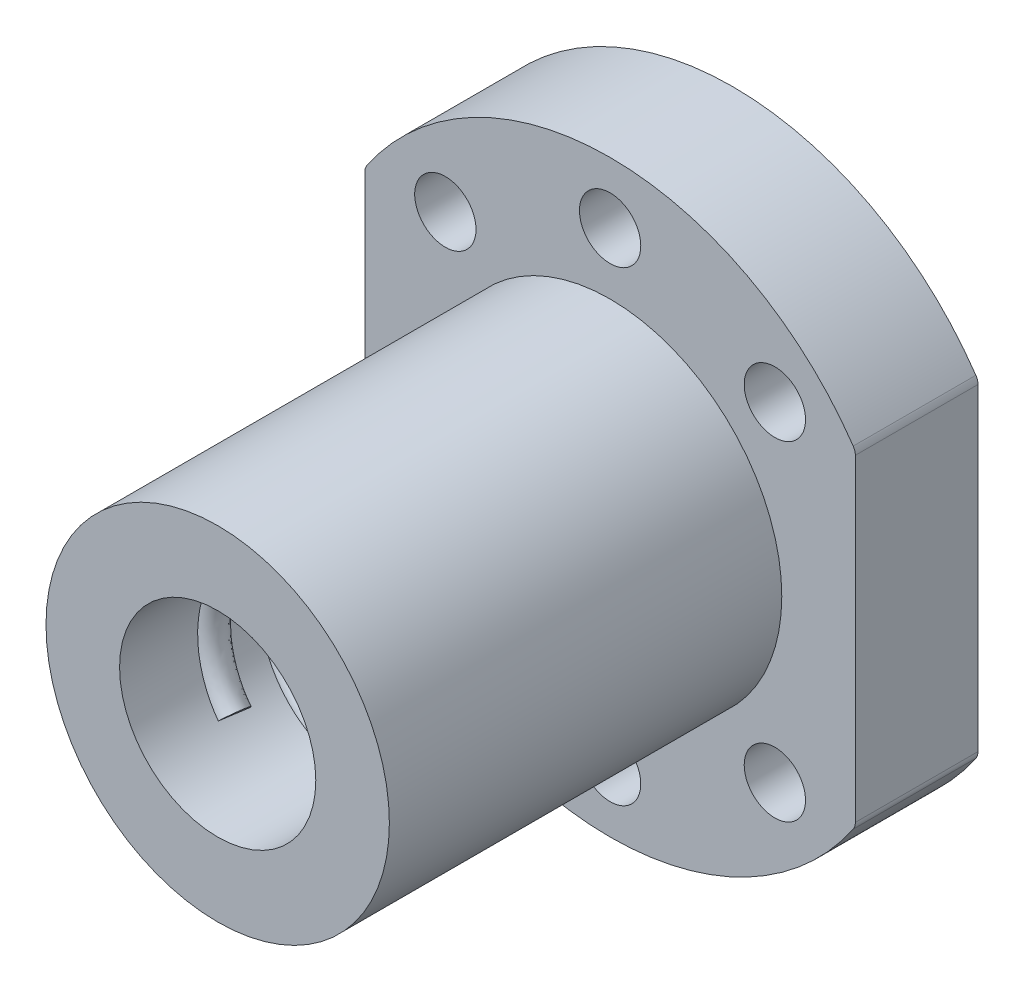
from build123d import *

# Parameters (mm, degrees)
SKETCH1_R           = 8
SKETCH1_R_2         = 2.5
BOSS_EXTRUDE1_DEPTH = 10
SKETCH2_R           = 14
SKETCH2_R_2         = 8
BOSS_EXTRUDE2_DEPTH = 32
SWEEP1_PITCH        = 5
SWEEP1_HEIGHT       = 25
SWEEP1_RADIUS       = 8
SWEEP1_START_ANGLE  = -135
SKETCH4_R           = 1.25
FILLET1_R           = 1


with BuildPart() as part:
    # Sketch1 → Boss-Extrude1 (new body)
    with BuildSketch(Plane.XY):
        with BuildLine():
            Line((-20, -13.266499161), (-20, 13.266499161))
            ThreePointArc((-20, 13.266499161), (0, 24), (20, 13.266499161))
            Line((20, 13.266499161), (20, -13.266499161))
            ThreePointArc((20, -13.266499161), (0, -24), (-20, -13.266499161))
        make_face()
        Circle(SKETCH1_R, mode=Mode.SUBTRACT)
        with Locations((-13.435028843, 13.435028843)):
            Circle(SKETCH1_R_2, mode=Mode.SUBTRACT)
        with Locations((0, 19)):
            Circle(SKETCH1_R_2, mode=Mode.SUBTRACT)
        with Locations((13.435028843, 13.435028843)):
            Circle(SKETCH1_R_2, mode=Mode.SUBTRACT)
        with Locations((13.435028843, -13.435028843)):
            Circle(SKETCH1_R_2, mode=Mode.SUBTRACT)
        with Locations((0, -19)):
            Circle(SKETCH1_R_2, mode=Mode.SUBTRACT)
        with Locations((-13.435028843, -13.435028843)):
            Circle(SKETCH1_R_2, mode=Mode.SUBTRACT)
    extrude(amount=BOSS_EXTRUDE1_DEPTH)

    # Sketch2 → Boss-Extrude2 (add)
    with BuildSketch(Plane.XY.offset(10)):
        Circle(SKETCH2_R)
        Circle(SKETCH2_R_2, mode=Mode.SUBTRACT)
    extrude(amount=BOSS_EXTRUDE2_DEPTH)

    # Sweep1: sweep along a helix
    with BuildLine() as sweep1_path:
        add(Helix(SWEEP1_PITCH, SWEEP1_HEIGHT, SWEEP1_RADIUS, center=(0, 0, 10), direction=(0, 0, 1), mode=Mode.PRIVATE).rotate(Axis((0, 0, 10), (0, 0, 1)), SWEEP1_START_ANGLE))
    # Sketch4 → Sweep1 (sweep)
    with BuildSketch(Plane(origin=(-5.656854249, -5.656854249, 10), x_dir=(0.069991793, -0.069991793, -0.99508909), z_dir=(0.703634244, -0.703634244, 0.098983342))):
        with Locations((0, -0.3)):
            Circle(SKETCH4_R)
    sweep(path=sweep1_path.line, is_frenet=True)

    # Fillet1
    fillet1_edges = [part.edges().sort_by_distance(p)[0] for p in [
        (-20, -13.266499161, 5),
        (-20, 13.266499161, 5),
        (20, 13.266499161, 5),
        (20, -13.266499161, 5),
    ]]
    fillet(fillet1_edges, radius=FILLET1_R)


solid = part.part
